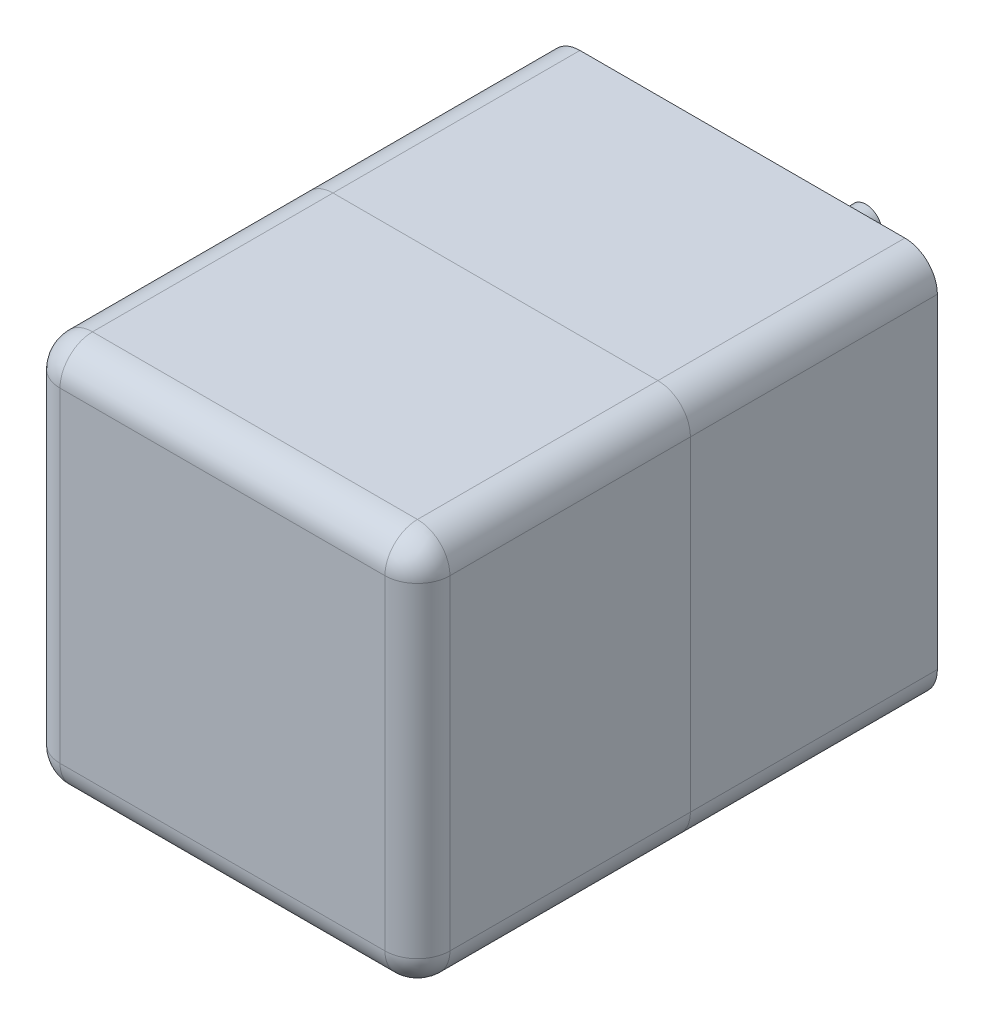
from build123d import *

# Parameters (mm, degrees)
SKETCH2_W           = 60
SKETCH2_H           = 60
BOSS_EXTRUDE1_DEPTH = 42
SKETCH3_W           = 60
SKETCH3_H           = 60
BOSS_EXTRUDE2_DEPTH = 38
FILLET1_R           = 5
FILLET2_R           = 5
FILLET3_R           = 5
SKETCH4_R           = 2.25
CUT_EXTRUDE1_DEPTH  = 10
SKETCH5_R           = 12
BOSS_EXTRUDE3_DEPTH = 4
SKETCH6_R           = 5
BOSS_EXTRUDE4_DEPTH = 28
CUT_EXTRUDE2_DEPTH  = 28
SKETCH8_R           = 5
CUT_EXTRUDE3_DEPTH  = 33
SKETCH9_R           = 2.5
BOSS_EXTRUDE5_DEPTH = 20


with BuildPart() as part:
    # Sketch2 → Boss-Extrude1 (new body)
    with BuildSketch(Plane.XY):
        with Locations((30, 30)):
            Rectangle(SKETCH2_W, SKETCH2_H)
    extrude(amount=BOSS_EXTRUDE1_DEPTH)

    # Fillet1
    fillet1_edges = [part.edges().sort_by_distance(p)[0] for p in [
        (0, 60, 21),
        (60, 60, 21),
        (60, 0, 21),
        (0, 0, 21),
    ]]
    fillet(fillet1_edges, radius=FILLET1_R)

    # Fillet3
    fillet3_edges = [part.edges().sort_by_distance(p)[0] for p in [
        (30, 0, 42),
        (0, 30, 42),
        (60, 30, 42),
        (30, 60, 42),
        (58.535533906, 58.535533906, 42),
        (1.464466094, 58.535533906, 42),
        (58.535533906, 1.464466094, 42),
        (1.464466094, 1.464466094, 42),
    ]]
    fillet(fillet3_edges, radius=FILLET3_R)


with BuildPart() as body_2:
    # Sketch3 → Boss-Extrude2 (new body)
    with BuildSketch(Plane(origin=(0, 0, 0), x_dir=(-1, 0, 0), z_dir=(0, 0, -1))):
        with Locations((-30, 30)):
            Rectangle(SKETCH3_W, SKETCH3_H)
    extrude(amount=BOSS_EXTRUDE2_DEPTH)

    # Fillet2
    fillet2_edges = [body_2.edges().sort_by_distance(p)[0] for p in [
        (60, 0, -19),
        (60, 60, -19),
        (0, 60, -19),
        (0, 0, -19),
    ]]
    fillet(fillet2_edges, radius=FILLET2_R)

    # Sketch4 → Cut-Extrude1 (cut)
    with BuildSketch(Plane(origin=(0, 0, -38), x_dir=(-1, 0, 0), z_dir=(0, 0, -1))):
        with Locations((-5.251262658, 54.748737342)):
            Circle(SKETCH4_R)
        with Locations((-54.748737342, 54.748737342)):
            Circle(SKETCH4_R)
        with Locations((-54.748737342, 5.251262658)):
            Circle(SKETCH4_R)
        with Locations((-5.251262658, 5.251262658)):
            Circle(SKETCH4_R)
    extrude(amount=-CUT_EXTRUDE1_DEPTH, mode=Mode.SUBTRACT)

    # Sketch5 → Boss-Extrude3 (add)
    with BuildSketch(Plane(origin=(0, 0, -38), x_dir=(-1, 0, 0), z_dir=(0, 0, -1))):
        with Locations((-30, 40)):
            Circle(SKETCH5_R)
    extrude(amount=BOSS_EXTRUDE3_DEPTH)

    # Sketch6 → Boss-Extrude4 (add)
    with BuildSketch(Plane(origin=(0, 0, -42), x_dir=(-1, 0, 0), z_dir=(0, 0, -1))):
        with Locations((-30, 40)):
            Circle(SKETCH6_R)
    extrude(amount=BOSS_EXTRUDE4_DEPTH)

    # Sketch7 → Cut-Extrude2 (cut)
    with BuildSketch(Plane(origin=(0, 42.5, 0), x_dir=(1, 0, 0), z_dir=(0, 1, 0))):
        with BuildLine():
            Line((28, 47), (28, 70))
            Line((28, 70), (32, 70))
            Line((32, 70), (32, 47))
            ThreePointArc((32, 47), (30, 45), (28, 47))
        make_face()
    extrude(amount=CUT_EXTRUDE2_DEPTH, mode=Mode.SUBTRACT)

    # Sketch8 → Cut-Extrude3 (cut)
    with BuildSketch(Plane(origin=(0, 0, -70), x_dir=(-1, 0, 0), z_dir=(0, 0, -1))):
        with Locations((-30, 40)):
            Circle(SKETCH8_R)
    extrude(amount=-CUT_EXTRUDE3_DEPTH, mode=Mode.SUBTRACT)

    # Sketch9 → Boss-Extrude5 (add)
    with BuildSketch(Plane(origin=(0, 0, -37), x_dir=(-1, 0, 0), z_dir=(0, 0, -1))):
        with Locations((-30, 40)):
            Circle(SKETCH9_R)
    extrude(amount=BOSS_EXTRUDE5_DEPTH)


solid = Compound([part.part, body_2.part])
